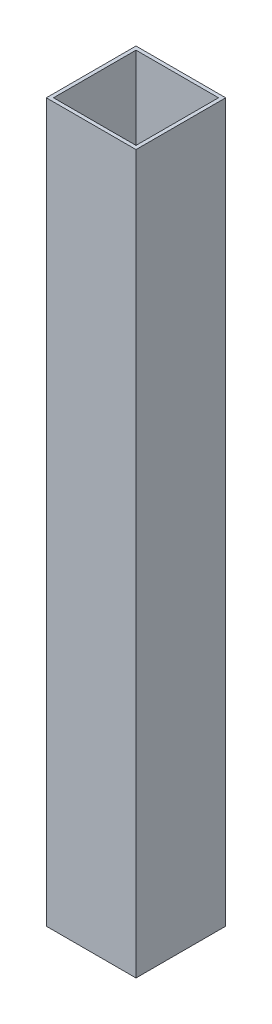
from build123d import *

# Parameters (mm, degrees)
SKETCH_1_W      = 100
SKETCH_1_H      = 100
SKETCH_1_W_2    = 92
SKETCH_1_H_2    = 92
EXTRUDE_1_DEPTH = 800


with BuildPart() as part:
    # Эскиз1 → Вытянуть-Тонкостенный1 (new body)
    with BuildSketch(Plane(origin=(0, 0, 0), x_dir=(1, 0, 0), z_dir=(0, 1, 0))):
        Rectangle(SKETCH_1_W, SKETCH_1_H)
        Rectangle(SKETCH_1_W_2, SKETCH_1_H_2, mode=Mode.SUBTRACT)
    extrude(amount=EXTRUDE_1_DEPTH)


solid = part.part
